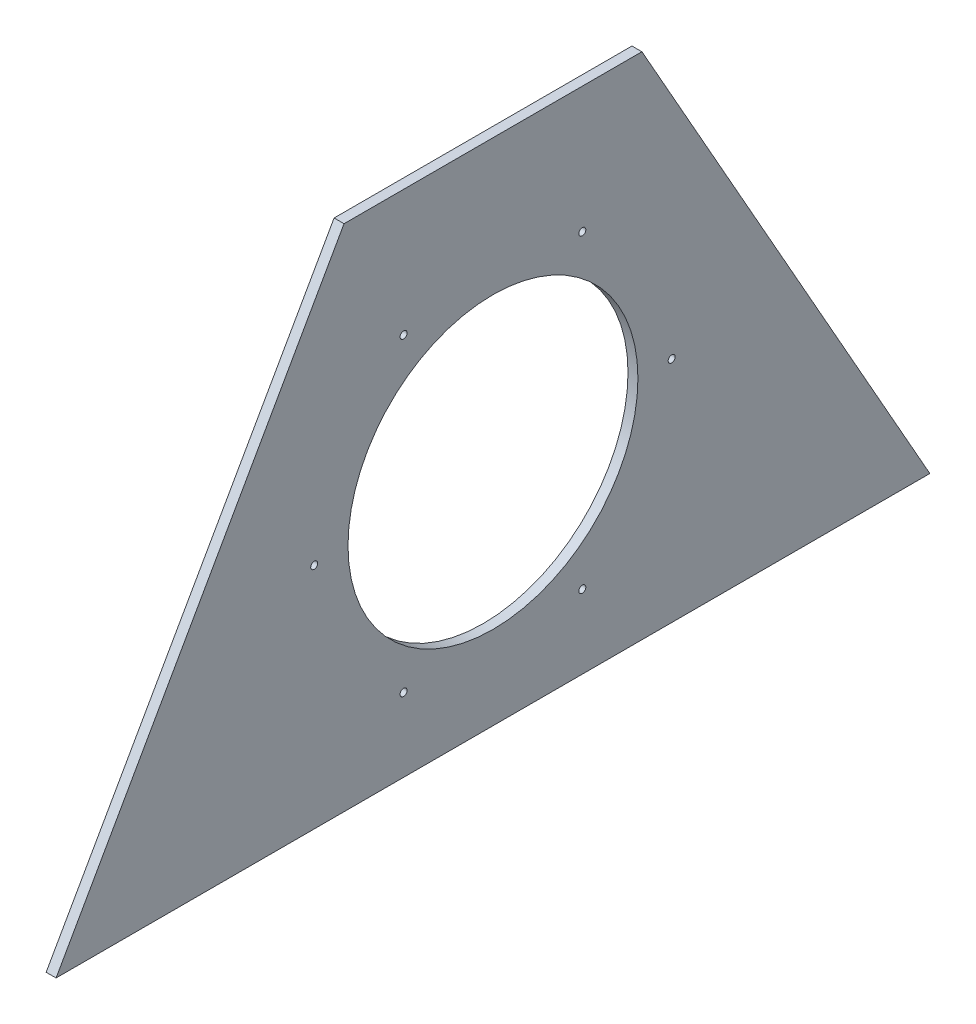
from build123d import *

# Parameters (mm, degrees)
BOSS_EXTRUDE1_DEPTH       = 6.35
SKETCH2_R                 = 92.71
CUT_EXTRUDE1_DEPTH        = 7.35
F_8_CLEARANCE_HOLE1_D     = 4.4958
F_8_CLEARANCE_HOLE1_DEPTH = 25.4
F_8_CLEARANCE_HOLE1_TIP   = 1.350674586


with BuildPart() as part:
    # Sketch1 → Boss-Extrude1 (new body)
    with BuildSketch(Plane(origin=(0, 0, 0), x_dir=(0, 0, -1), z_dir=(1, 0, 0))):
        Polygon((0, 0), (558.8, 0), (374.65, 325.68545203), (184.15, 325.68545203), align=None)
    extrude(amount=BOSS_EXTRUDE1_DEPTH)

    # Sketch2 → Cut-Extrude1 (cut, through all)
    with BuildSketch(Plane(origin=(6.35, 0, 0), x_dir=(0, 0, -1), z_dir=(1, 0, 0))):
        with Locations((279.4, 146.05)):
            Circle(SKETCH2_R)
    extrude(amount=-CUT_EXTRUDE1_DEPTH, mode=Mode.SUBTRACT)

    # #8 Clearance Hole1
    with Locations(Plane.ZY):
        with Locations((-336.55, 245.036703653), (-222.25, 245.036703653), (-165.1, 146.05), (-222.25, 47.063296347), (-336.55, 47.063296347), (-393.7, 146.05)):
            Hole(F_8_CLEARANCE_HOLE1_D / 2, depth=F_8_CLEARANCE_HOLE1_DEPTH)
            with Locations((0, 0, -(F_8_CLEARANCE_HOLE1_DEPTH + F_8_CLEARANCE_HOLE1_TIP / 2))):  # 118° drill point
                Cone(0, F_8_CLEARANCE_HOLE1_D / 2, F_8_CLEARANCE_HOLE1_TIP, mode=Mode.SUBTRACT)


solid = part.part
